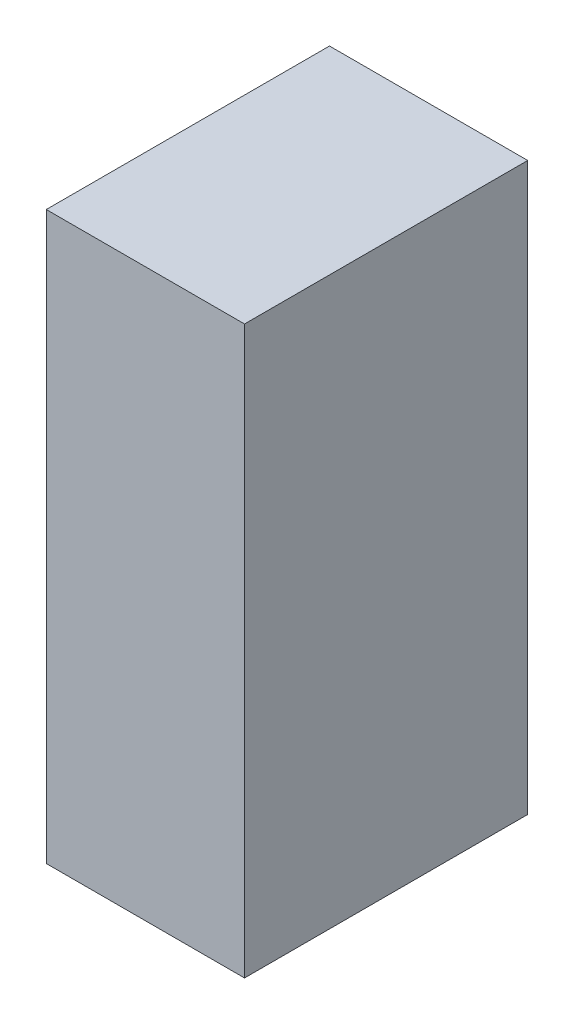
from build123d import *

# Parameters (mm, degrees)
SCHIZZO1_W                   = 140
SCHIZZO1_H                   = 400
ESTRUSIONE_ESTRUSIONE1_DEPTH = 200


with BuildPart() as part:
    # Schizzo1 → Estrusione-Estrusione1 (new body)
    with BuildSketch(Plane.XY):
        with Locations((0, -200)):
            Rectangle(SCHIZZO1_W, SCHIZZO1_H)
    extrude(amount=ESTRUSIONE_ESTRUSIONE1_DEPTH)


solid = part.part
